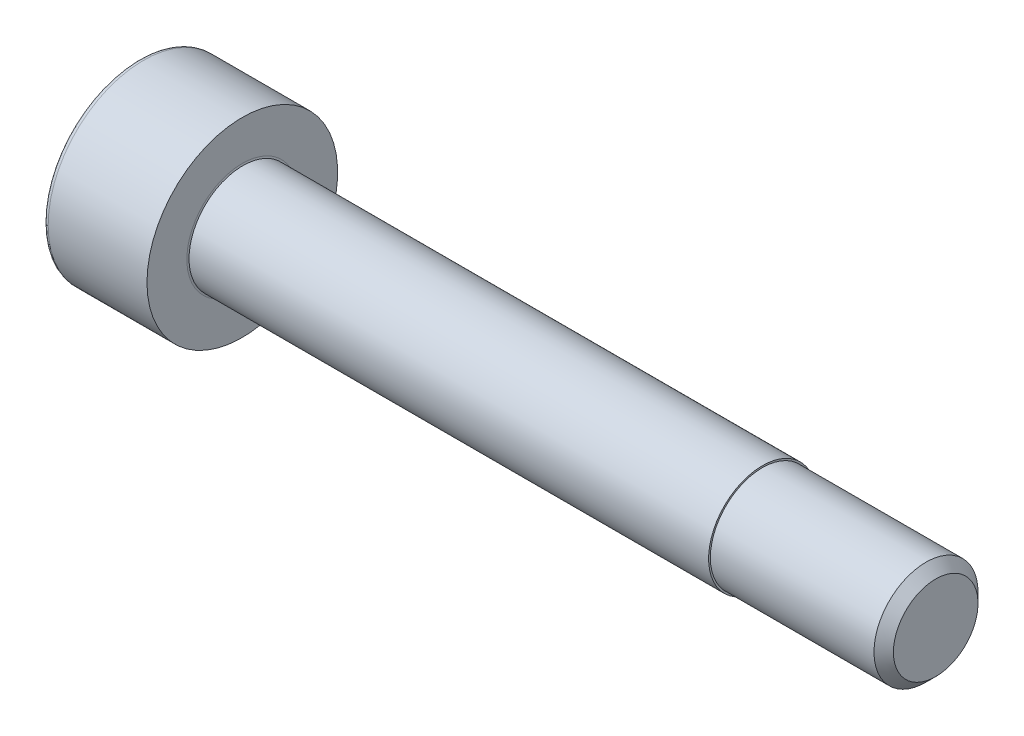
from build123d import *

# Parameters (mm, degrees)
FILLET1_R           = 0.1
FILLET2_R           = 0.15
HEX_2_DEPTH         = 1.3
SKETCH4_R           = 1.55
BOSS_EXTRUDE1_DEPTH = 15


with BuildPart() as part:
    # BodySke → Base-Revolve (revolve)
    with BuildSketch(Plane.XY):
        Polygon((0, 0), (0, 2.75), (3, 2.75), (3, 1.5), (22.7195, 1.5), (23, 1.2195), (23, 0), align=None)
    revolve(axis=Axis((-31.75, 0, 0), (1, 0, 0)))

    # Fillet1
    fillet1_edges = [part.edges().sort_by_distance(p)[0] for p in [
        (3, -1.5, 0),
    ]]
    fillet(fillet1_edges, radius=FILLET1_R)

    # Fillet2
    fillet2_edges = [part.edges().sort_by_distance(p)[0] for p in [
        (0, -2.75, 0),
    ]]
    fillet(fillet2_edges, radius=FILLET2_R)

    # Sketch2 → Hex-PreBroach (revolve, cut)
    with BuildSketch(Plane.XY):
        Polygon((0, 1.28), (1.3, 1.28), (2.039008345, 0), (0, 0), align=None)
    revolve(axis=Axis((0, 0, 0), (1, 0, 0)), mode=Mode.SUBTRACT)

    # Sketch3 → Hex 2 (cut)
    with BuildSketch(Plane(origin=(0, 0, 0), x_dir=(0, 0.5, 0.866025404), z_dir=(-1, 0, 0))):
        Polygon((0.739008345, 1.28), (-0.739008345, 1.28), (-1.478016689, 0), (-0.739008345, -1.28), (0.739008345, -1.28), (1.478016689, 0), align=None)
    extrude(amount=-HEX_2_DEPTH, mode=Mode.SUBTRACT)

    # Sketch4 → Boss-Extrude1 (add)
    with BuildSketch(Plane(origin=(3, 0, 0), x_dir=(0, 0, -1), z_dir=(1, 0, 0))):
        Circle(SKETCH4_R)
    extrude(amount=BOSS_EXTRUDE1_DEPTH)


solid = part.part
